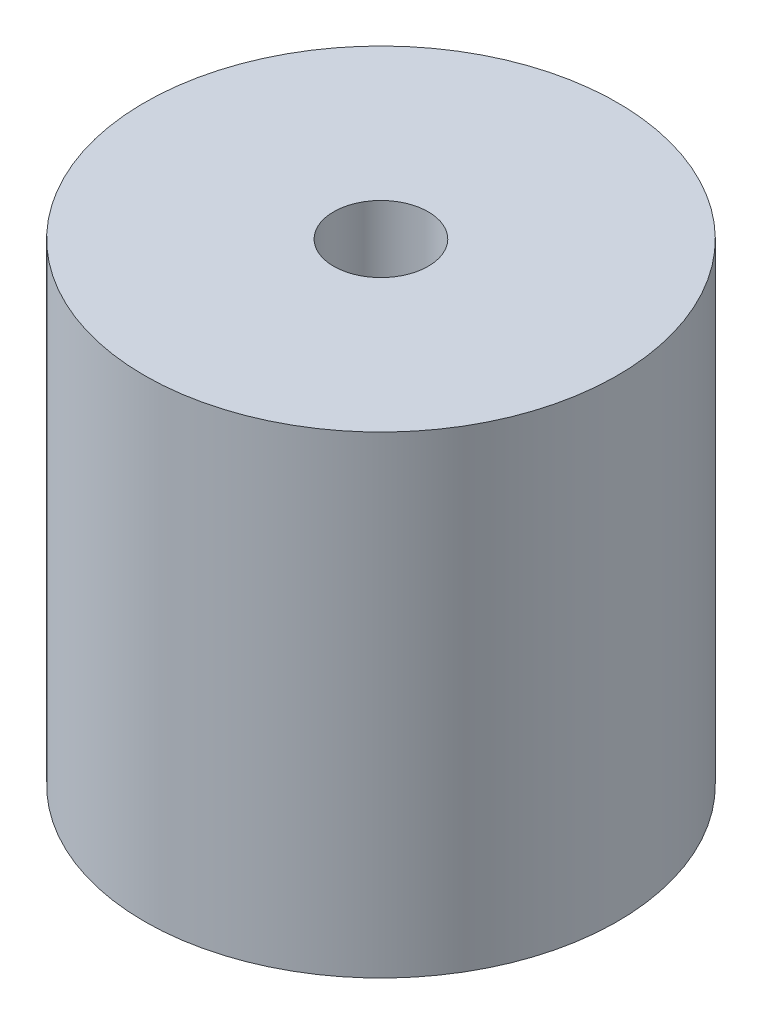
from build123d import *

# Parameters (mm, degrees)
SKETCH1_R           = 10
BOSS_EXTRUDE1_DEPTH = 20
SKETCH2_R           = 2
CUT_EXTRUDE1_DEPTH  = 10


with BuildPart() as part:
    # Sketch1 → Boss-Extrude1 (new body)
    with BuildSketch(Plane(origin=(0, 0, 0), x_dir=(1, 0, 0), z_dir=(0, 1, 0))):
        Circle(SKETCH1_R)
    extrude(amount=BOSS_EXTRUDE1_DEPTH)

    # Sketch2 → Cut-Extrude1 (cut)
    with BuildSketch(Plane(origin=(0, 20, 0), x_dir=(1, 0, 0), z_dir=(0, 1, 0))):
        Circle(SKETCH2_R)
    extrude(amount=-CUT_EXTRUDE1_DEPTH, mode=Mode.SUBTRACT)


solid = part.part
